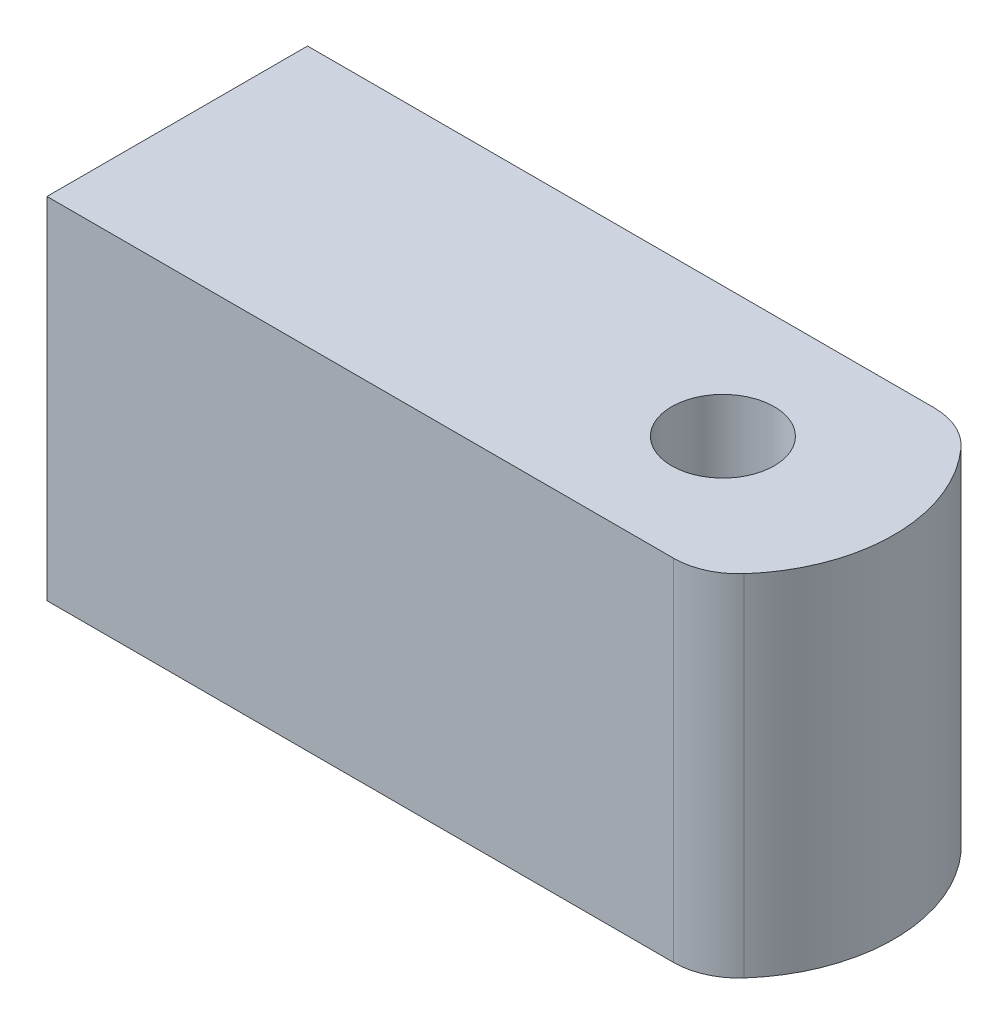
from build123d import *

# Parameters (mm, degrees)
BOSS_EXTRUDE1_DEPTH      = 19
BOSS_EXTRUDE1_DEPTH_BACK = 4
SKETCH2_R                = 3.15
CUT_EXTRUDE1_DEPTH       = 32
SKETCH3_W                = 10.5
SKETCH3_H                = 10.5
CUT_EXTRUDE2_DEPTH       = 24
FILLET1_R                = 4
SKETCH4_W                = 16
SKETCH4_H                = 23
SKETCH4_W_2              = 10.5
SKETCH4_H_2              = 10.5
BOSS_EXTRUDE2_DEPTH      = 15
SKETCH5_W                = 16
SKETCH5_H                = 1.25
SKETCH5_H_2              = 0.25
CUT_EXTRUDE3_DEPTH       = 48


with BuildPart() as part:
    # Sketch1 → Boss-Extrude1 (new body, two sides)
    with BuildSketch(Plane(origin=(0, 0, 0), x_dir=(1, 0, 0), z_dir=(0, 1, 0))) as boss_extrude1_sk:
        with BuildLine():
            Line((0, 0), (0, 16))
            Line((0, 16), (25.005148766, 16))
            ThreePointArc((25.005148766, 16), (29.005148766, 8), (25.005148766, 0))
            Line((25.005148766, 0), (0, 0))
        make_face()
    extrude(amount=BOSS_EXTRUDE1_DEPTH)
    extrude(boss_extrude1_sk.sketch, amount=-BOSS_EXTRUDE1_DEPTH_BACK)

    # Sketch2 → Cut-Extrude1 (cut)
    with BuildSketch(Plane(origin=(0, 19, 0), x_dir=(1, 0, 0), z_dir=(0, 1, 0))):
        with Locations((18.505148766, 8)):
            Circle(SKETCH2_R)
    extrude(amount=-CUT_EXTRUDE1_DEPTH, mode=Mode.SUBTRACT)

    # Sketch3 → Cut-Extrude2 (cut)
    with BuildSketch(Plane.ZY):
        with Locations((-8, 8)):
            Rectangle(SKETCH3_W, SKETCH3_H)
    extrude(amount=-CUT_EXTRUDE2_DEPTH, mode=Mode.SUBTRACT)

    # Fillet1
    fillet1_edges = [part.edges().sort_by_distance(p)[0] for p in [
        (25.005148766, 7.5, -16),
        (25.005148766, 7.5, 0),
    ]]
    fillet(fillet1_edges, radius=FILLET1_R)

    # Sketch4 → Boss-Extrude2 (add)
    with BuildSketch(Plane.ZY):
        with Locations((-8, 7.5)):
            Rectangle(SKETCH4_W, SKETCH4_H)
        with Locations((-8, 8)):
            Rectangle(SKETCH4_W_2, SKETCH4_H_2, mode=Mode.SUBTRACT)
    extrude(amount=BOSS_EXTRUDE2_DEPTH)

    # Sketch5 → Cut-Extrude3 (cut)
    with BuildSketch(Plane.ZY.offset(15)):
        with Locations((-8, -3.375)):
            Rectangle(SKETCH5_W, SKETCH5_H)
        with Locations((-8, 18.875)):
            Rectangle(SKETCH5_W, SKETCH5_H_2)
    extrude(amount=-CUT_EXTRUDE3_DEPTH, mode=Mode.SUBTRACT)


solid = part.part
